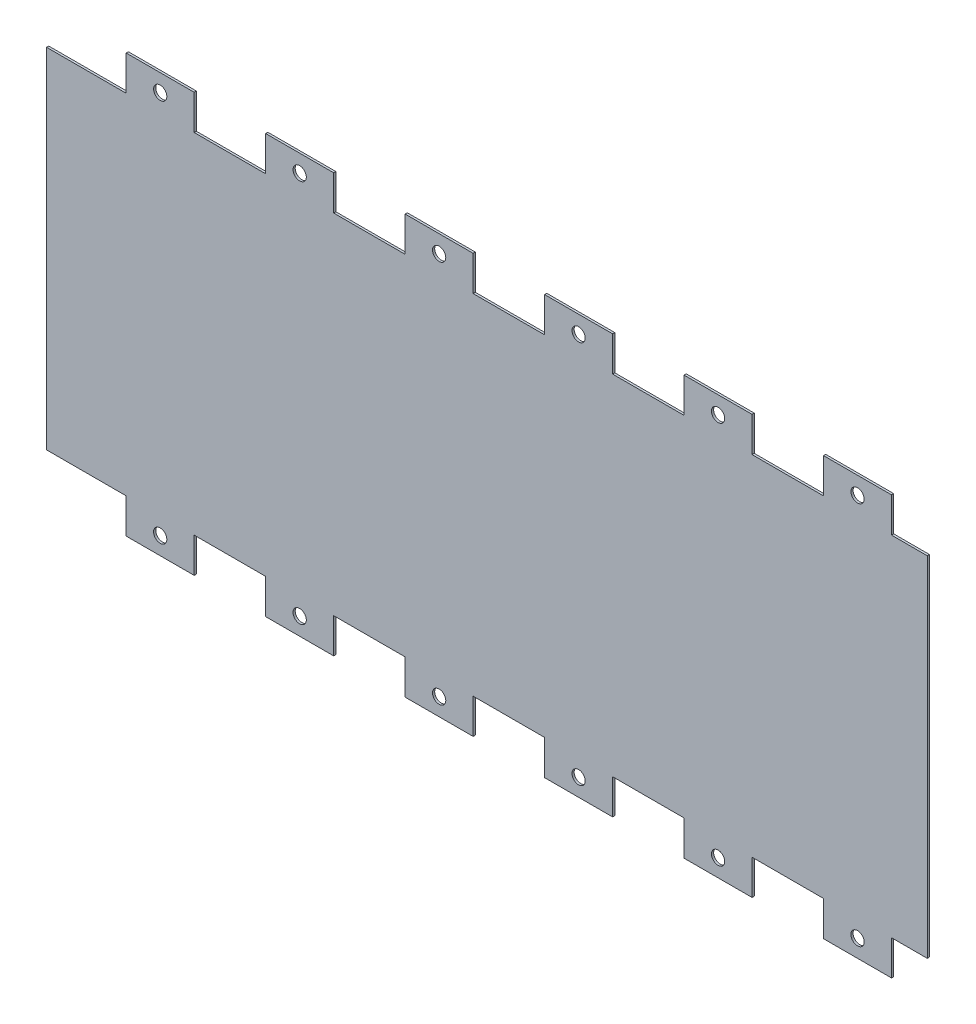
from build123d import *

# Parameters (mm, degrees)
SKETCH1_W           = 320.802
SKETCH1_H           = 152.4
BOSS_EXTRUDE1_DEPTH = 0.79375
SKETCH2_W           = 13.0175
SKETCH2_H           = 12.7
SKETCH2_W_2         = 26.035
SKETCH2_W_3         = 2.9845
CUT_EXTRUDE1_DEPTH  = 1.79375
SKETCH3_R           = 2.413
CUT_EXTRUDE2_DEPTH  = 1.79375


with BuildPart() as part:
    # Sketch1 → Boss-Extrude1 (new body)
    with BuildSketch(Plane.XY):
        with Locations((160.401, 76.2)):
            Rectangle(SKETCH1_W, SKETCH1_H)
    extrude(amount=BOSS_EXTRUDE1_DEPTH)

    # Sketch2 → Cut-Extrude1 (cut, through all)
    with BuildSketch(Plane.XY.offset(0.79375)):
        with Locations((314.29325, 146.05)):
            Rectangle(SKETCH2_W, SKETCH2_H)
        with Locations((270.002, 146.05)):
            Rectangle(SKETCH2_W_2, SKETCH2_H)
        with Locations((219.202, 146.05)):
            Rectangle(SKETCH2_W_2, SKETCH2_H)
        with Locations((168.402, 146.05)):
            Rectangle(SKETCH2_W_2, SKETCH2_H)
        with Locations((117.602, 146.05)):
            Rectangle(SKETCH2_W_2, SKETCH2_H)
        with Locations((66.802, 146.05)):
            Rectangle(SKETCH2_W_2, SKETCH2_H)
        with Locations((16.002, 146.05)):
            Rectangle(SKETCH2_W_2, SKETCH2_H)
        with Locations((1.49225, 146.05)):
            Rectangle(SKETCH2_W_3, SKETCH2_H)
        with Locations((1.49225, 6.35)):
            Rectangle(SKETCH2_W_3, SKETCH2_H)
        with Locations((16.002, 6.35)):
            Rectangle(SKETCH2_W_2, SKETCH2_H)
        with Locations((66.802, 6.35)):
            Rectangle(SKETCH2_W_2, SKETCH2_H)
        with Locations((117.602, 6.35)):
            Rectangle(SKETCH2_W_2, SKETCH2_H)
        with Locations((168.402, 6.35)):
            Rectangle(SKETCH2_W_2, SKETCH2_H)
        with Locations((219.202, 6.35)):
            Rectangle(SKETCH2_W_2, SKETCH2_H)
        with Locations((270.002, 6.35)):
            Rectangle(SKETCH2_W_2, SKETCH2_H)
        with Locations((314.29325, 6.35)):
            Rectangle(SKETCH2_W, SKETCH2_H)
    extrude(amount=-CUT_EXTRUDE1_DEPTH, mode=Mode.SUBTRACT)

    # Sketch3 → Cut-Extrude2 (cut, through all)
    with BuildSketch(Plane.XY.offset(0.79375)):
        with Locations((41.402, 146.05)):
            Circle(SKETCH3_R)
        with Locations((92.202, 146.05)):
            Circle(SKETCH3_R)
        with Locations((143.002, 146.05)):
            Circle(SKETCH3_R)
        with Locations((193.802, 146.05)):
            Circle(SKETCH3_R)
        with Locations((244.602, 146.05)):
            Circle(SKETCH3_R)
        with Locations((295.402, 146.05)):
            Circle(SKETCH3_R)
        with Locations((92.202, 6.35)):
            Circle(SKETCH3_R)
        with Locations((143.002, 6.35)):
            Circle(SKETCH3_R)
        with Locations((193.802, 6.35)):
            Circle(SKETCH3_R)
        with Locations((244.602, 6.35)):
            Circle(SKETCH3_R)
        with Locations((295.402, 6.35)):
            Circle(SKETCH3_R)
        with Locations((41.402, 6.35)):
            Circle(SKETCH3_R)
    extrude(amount=-CUT_EXTRUDE2_DEPTH, mode=Mode.SUBTRACT)


solid = part.part
